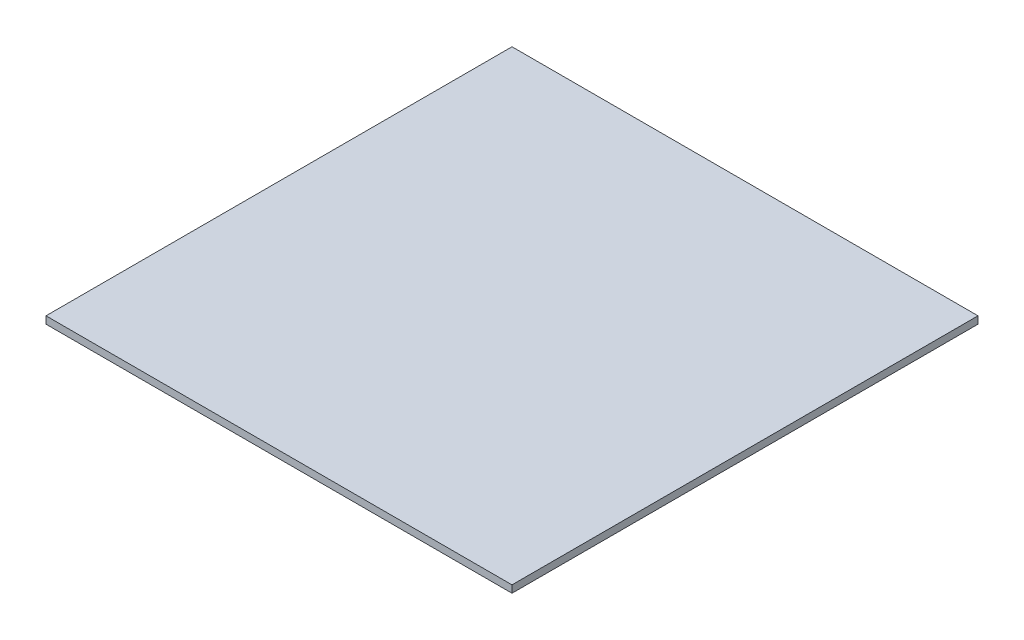
from build123d import *

# Parameters (mm, degrees)
SKETCH1_W           = 203.2
SKETCH1_H           = 203.2
BOSS_EXTRUDE1_DEPTH = 3.175


with BuildPart() as part:
    # Sketch1 → Boss-Extrude1 (new body)
    with BuildSketch(Plane(origin=(0, 0, 0), x_dir=(1, 0, 0), z_dir=(0, 1, 0))):
        Rectangle(SKETCH1_W, SKETCH1_H)
    extrude(amount=BOSS_EXTRUDE1_DEPTH)


solid = part.part
